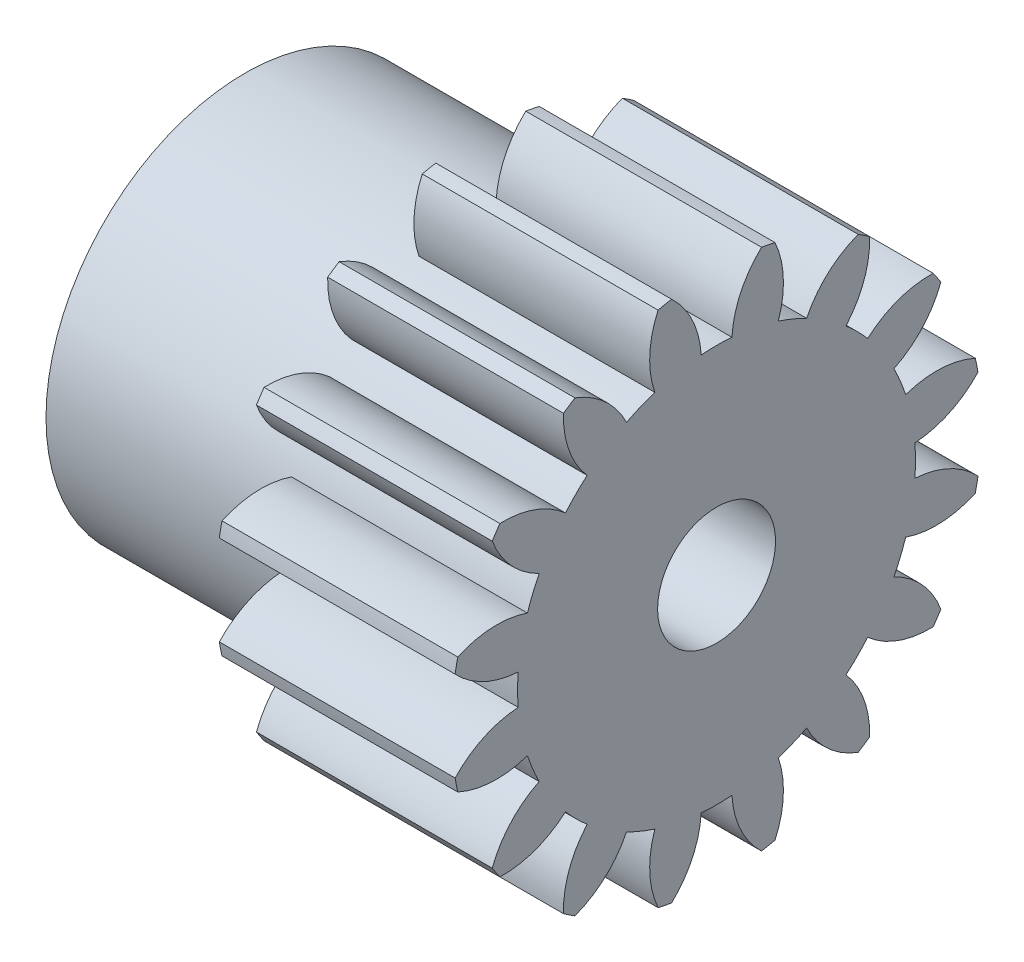
from build123d import *
from build123d.topology import SkipClean

# Parameters (mm, degrees)
BASPROSKE_W      = 10
BASPROSKE_H      = 11.25
TOOTHCUT_DEPTH   = 19.791620473
TEETHCUTS_COUNT  = 16
TEETHCUTS_ANGLE  = 337.5
HUBNEAONESKE_R   = 8.4365
HUBNEARONE_DEPTH = 10.0000508
BORSKE_R         = 2.5
BORE_DEPTH       = 20.0000508


with BuildPart() as part:
    # BasProSke → Base-Revolve (revolve)
    with BuildSketch(Plane(origin=(0, 0, 0), x_dir=(1, 0, 0), z_dir=(0, 1, 0)), mode=Mode.PRIVATE) as base_revolve_sk:
        with Locations((5, 5.625)):
            Rectangle(BASPROSKE_W, BASPROSKE_H)
    revolve(base_revolve_sk.sketch.rotate(Axis((-10, 0, 0), (1, 0, 0)), 180), axis=Axis((-10, 0, 0), (1, 0, 0)))

    # TooCutSke → ToothCut (cut, through all)
    with BuildSketch(Plane(origin=(0, 0, 0), x_dir=(0, 0, -1), z_dir=(1, 0, 0))):
        with BuildLine():
            ThreePointArc((0.651061533, 8.411340626), (0, 8.4365), (-0.651061533, 8.411340626))
            ThreePointArc((-0.651061533, 8.411340626), (-1.029874156, 9.883978829), (-1.930926138, 11.108832945))
            ThreePointArc((-1.930926138, 11.108832945), (0, 11.2754), (1.930926138, 11.108832945))
            ThreePointArc((1.930926138, 11.108832945), (1.029874156, 9.883978829), (0.651061533, 8.411340626))
        make_face()
    toothcut = extrude(amount=TOOTHCUT_DEPTH, mode=Mode.SUBTRACT)

    # TeethCuts: ToothCut ×16 about axis
    teethcuts_axis = Axis((-10, 0, 0), (1, 0, 0))
    for i in range(1, TEETHCUTS_COUNT):
        add(toothcut.rotate(teethcuts_axis, i * TEETHCUTS_ANGLE / (TEETHCUTS_COUNT - 1)), mode=Mode.SUBTRACT)

    # HubNeaOneSke → HubNearOne (add)
    with SkipClean():  # the faces are left unmerged after this step: merging them gives an invalid solid
        with BuildSketch(Plane.ZY):
            Circle(HUBNEAONESKE_R)
        extrude(amount=HUBNEARONE_DEPTH)

    # BorSke → Bore (cut, symmetric)
    with SkipClean():  # the faces are left unmerged after this step: merging them gives an invalid solid
        with BuildSketch(Plane(origin=(0, 0, 0), x_dir=(0, 0, -1), z_dir=(1, 0, 0))):
            with Locations(Location((0, 0, 0), (0, 0, 180))):
                Circle(BORSKE_R)
        extrude(amount=BORE_DEPTH, both=True, mode=Mode.SUBTRACT)


solid = part.part
